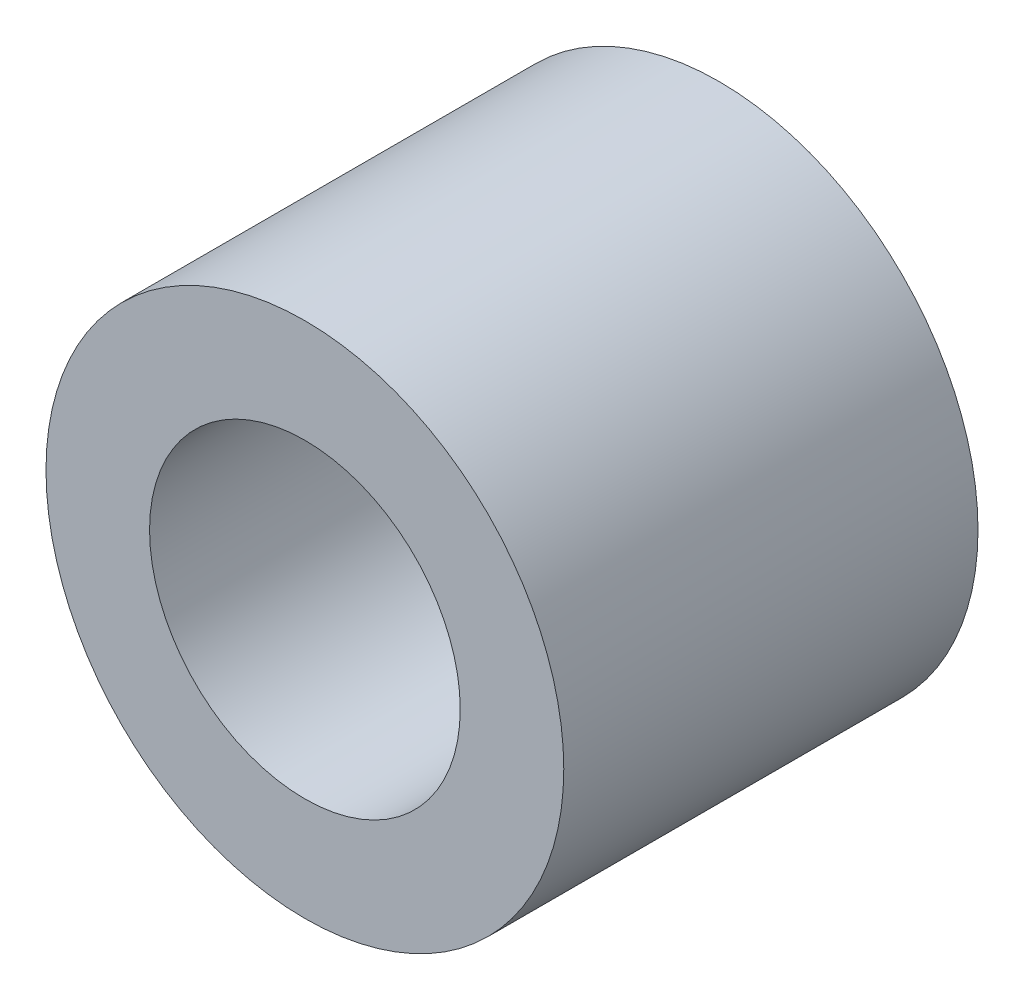
from build123d import *

# Parameters (mm, degrees)
SKETCH1_R      = 3.96875
SKETCH1_R_2    = 2.38125
EXTRUDE1_DEPTH = 3.175


with BuildPart() as part:
    # Sketch1 → Extrude1 (new body, symmetric)
    with BuildSketch(Plane.XY):
        Circle(SKETCH1_R)
        Circle(SKETCH1_R_2, mode=Mode.SUBTRACT)
    extrude(amount=EXTRUDE1_DEPTH, both=True)


solid = part.part
